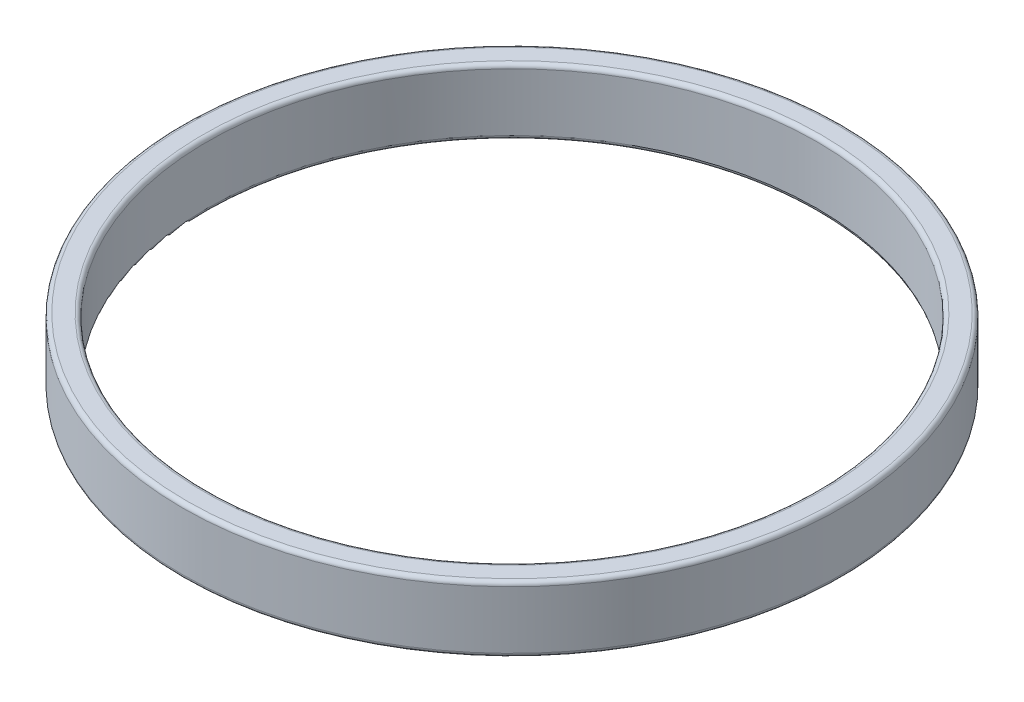
from build123d import *

# Parameters (mm, degrees)
SKETCH1_W = 1.5
SKETCH1_H = 4
FILLET1_R = 0.25


with BuildPart() as part:
    # Sketch1 → Revolve1 (revolve)
    with BuildSketch(Plane.XY):
        with Locations((-19.25, 0)):
            Rectangle(SKETCH1_W, SKETCH1_H)
    revolve(axis=Axis((0, 0, 0), (0, 1, 0)))

    # Fillet1
    fillet1_edges = [part.edges().sort_by_distance(p)[0] for p in [
        (20, 2, 0),
        (18.5, 2, 0),
        (18.5, -2, 0),
        (20, -2, 0),
    ]]
    fillet(fillet1_edges, radius=FILLET1_R)


solid = part.part
